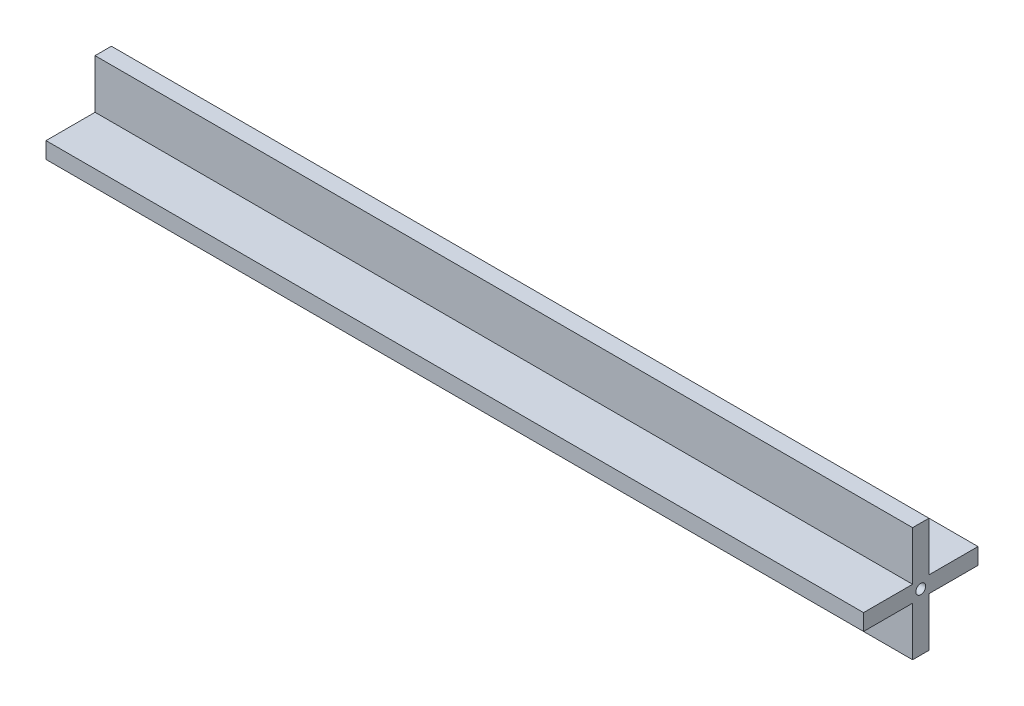
from build123d import *

# Parameters (mm, degrees)
SKETCH1_R           = 1.5
BOSS_EXTRUDE1_DEPTH = 250


with BuildPart() as part:
    # Sketch1 → Boss-Extrude1 (new body)
    with BuildSketch(Plane(origin=(0, 0, 0), x_dir=(0, 0, -1), z_dir=(1, 0, 0))):
        Polygon((17.5, 2.5), (2.5, 2.5), (2.5, 17.5), (-2.5, 17.5), (-2.5, 2.5), (-17.5, 2.5), (-17.5, -2.5), (-2.5, -2.5), (-2.5, -17.5), (2.5, -17.5), (2.5, -2.5), (17.5, -2.5), align=None)
        Circle(SKETCH1_R, mode=Mode.SUBTRACT)
    extrude(amount=BOSS_EXTRUDE1_DEPTH)


solid = part.part
